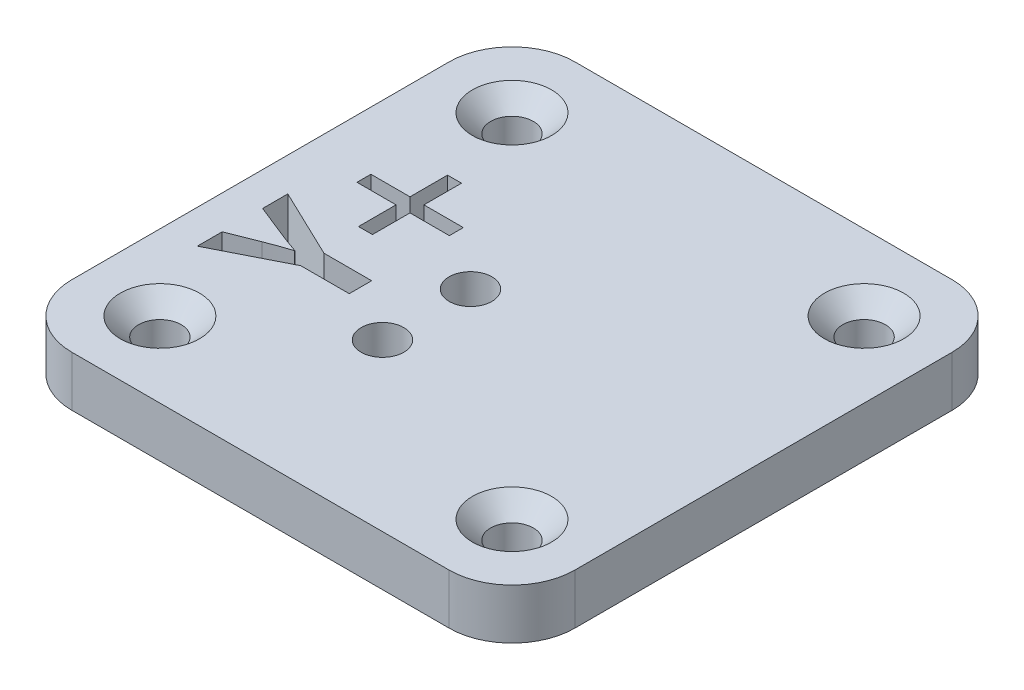
from build123d import *

# Parameters (mm, degrees)
BOSS_EXTRUDE1_DEPTH                                 = 4
CSK_FOR_M3_COUNTERSUNK_FLAT_HEAD_SCREW1_D           = 3.4
CSK_FOR_M3_COUNTERSUNK_FLAT_HEAD_SCREW1_CSINK_D     = 6.3
CSK_FOR_M3_COUNTERSUNK_FLAT_HEAD_SCREW1_CSINK_ANGLE = 90
CSK_FOR_M3_COUNTERSUNK_FLAT_HEAD_SCREW2_D           = 3.4
CSK_FOR_M3_COUNTERSUNK_FLAT_HEAD_SCREW2_CSINK_D     = 6.3
CSK_FOR_M3_COUNTERSUNK_FLAT_HEAD_SCREW2_CSINK_ANGLE = 90
CUT_EXTRUDE1_DEPTH                                  = 4


with BuildPart() as part:
    # Sketch1 → Boss-Extrude1 (new body)
    with BuildSketch(Plane(origin=(0, 0, 0), x_dir=(1, 0, 0), z_dir=(0, 1, 0))):
        with BuildLine():
            Line((-15, -20), (15, -20))
            ThreePointArc((15, -20), (18.535533906, -18.535533906), (20, -15))
            Line((20, -15), (20, 15))
            ThreePointArc((20, 15), (18.535533906, 18.535533906), (15, 20))
            Line((15, 20), (-15, 20))
            ThreePointArc((-15, 20), (-18.535533906, 18.535533906), (-20, 15))
            Line((-20, 15), (-20, -15))
            ThreePointArc((-20, -15), (-18.535533906, -18.535533906), (-15, -20))
        make_face()
    extrude(amount=BOSS_EXTRUDE1_DEPTH)

    # CSK for M3 Countersunk Flat Head Screw1 (through all)
    with Locations(Plane(origin=(-14, 4, -14), x_dir=(0, 0, 1), z_dir=(0, 1, 0))):
        with Locations((0, 0), (0, 28), (28, 28), (28, 0)):
            CounterSinkHole(CSK_FOR_M3_COUNTERSUNK_FLAT_HEAD_SCREW1_D / 2, CSK_FOR_M3_COUNTERSUNK_FLAT_HEAD_SCREW1_CSINK_D / 2, counter_sink_angle=CSK_FOR_M3_COUNTERSUNK_FLAT_HEAD_SCREW1_CSINK_ANGLE)

    # CSK for M3 Countersunk Flat Head Screw2 (through all)
    with Locations(Plane(origin=(0, 0, 0), x_dir=(-1, 0, 0), z_dir=(0, -1, 0))):
        with Locations((3.5, 0.2), (3.5, -6.8)):
            CounterSinkHole(CSK_FOR_M3_COUNTERSUNK_FLAT_HEAD_SCREW2_D / 2, CSK_FOR_M3_COUNTERSUNK_FLAT_HEAD_SCREW2_CSINK_D / 2, counter_sink_angle=CSK_FOR_M3_COUNTERSUNK_FLAT_HEAD_SCREW2_CSINK_ANGLE)

    # Sketch7 → Cut-Extrude1 (cut)
    with BuildSketch(Plane(origin=(0, 4, 0), x_dir=(1, 0, 0), z_dir=(0, 1, 0))):
        Polygon((-12.263344174, 7.136676397), (-11.15360872, 7.136676397), (-11.15360872, 4.150967788), (-8.022255789, 4.150967788), (-8.022255789, 3.041232335), (-11.15360872, 3.041232335), (-11.15360872, 0.055523726), (-12.263344174, 0.055523726), (-12.263344174, 3.041232335), (-15.370423051, 3.041232335), (-15.370423051, 4.150967788), (-12.263344174, 4.150967788), align=None)
        with BuildLine():
            add(Edge.make_bspline(
                [(-15.043692162, -4.829120306), (-14.880436161, -4.763861041), (-14.5584639, -4.635157209), (-14.077627456, -4.457919156), (-13.607003536, -4.298363006), (-13.296000815, -4.200734384), (-13.143053989, -4.152721981)],
                knots=[0, 0, 0, 0, 0.000527431, 0.001040195, 0.001537166, 0.002018074, 0.002018074, 0.002018074, 0.002018074], degree=3))
            Line((-13.143053989, -4.152721981), (-13.142217189, -4.129946622))
            add(Edge.make_bspline(
                [(-13.142217189, -4.129946622), (-13.300142366, -4.076064923), (-13.613682824, -3.969089626), (-14.081290903, -3.798233499), (-14.553659216, -3.619087412), (-14.870442844, -3.493499611), (-15.032410797, -3.429287962)],
                knots=[0, 0, 0, 0, 0.000500579, 0.000993836, 0.001493443, 0.002016132, 0.002016132, 0.002016132, 0.002016132], degree=3))
            Line((-15.032410797, -3.429287962), (-17.320356965, -2.510346296))
            Line((-17.320356965, -2.510346296), (-17.320356965, -0.507736863))
            Line((-17.320356965, -0.507736863), (-11.797862272, -3.15360872))
            Line((-11.797862272, -3.15360872), (-8.007023631, -3.15360872))
            Line((-8.007023631, -3.15360872), (-8.007023631, -4.937612774))
            Line((-8.007023631, -4.937612774), (-11.858418799, -4.937612774))
            Line((-11.858418799, -4.937612774), (-17.320356965, -7.7048549))
            Line((-17.320356965, -7.7048549), (-17.320356965, -5.726519521))
            Line((-17.320356965, -5.726519521), (-15.043692162, -4.829120306))
        make_face()
    extrude(amount=-CUT_EXTRUDE1_DEPTH, mode=Mode.SUBTRACT)


solid = part.part
